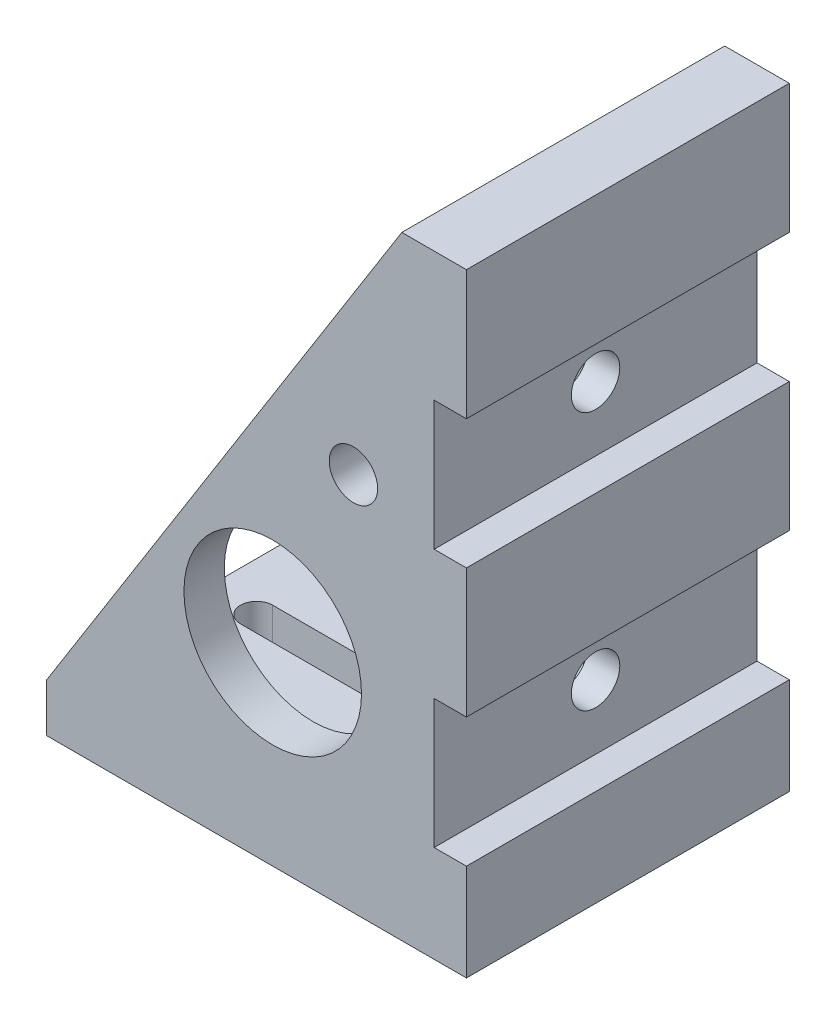
from build123d import *

# Parameters (mm, degrees)
BOSS_EXTRUDE1_DEPTH = 20
SKETCH2_W           = 20
SKETCH2_H           = 8
CUT_EXTRUDE1_DEPTH  = 2
SKETCH4_W           = 15
SKETCH4_H           = 35
CUT_EXTRUDE2_DEPTH  = 22
SKETCH5_R           = 1.5
SKETCH5_R_2         = 5.5
CUT_EXTRUDE3_DEPTH  = 20
SKETCH6_R           = 1.5
CUT_EXTRUDE4_DEPTH  = 2
CUT_EXTRUDE5_DEPTH  = 3


with BuildPart() as part:
    # Sketch1 → Boss-Extrude1 (new body)
    with BuildSketch(Plane.XY):
        Polygon((-13, 0), (13, 0), (13, 38), (9, 38), (-13, 3), align=None)
    extrude(amount=BOSS_EXTRUDE1_DEPTH)

    # Sketch2 → Cut-Extrude1 (cut)
    with BuildSketch(Plane(origin=(13, 0, 0), x_dir=(0, 0, -1), z_dir=(1, 0, 0))):
        with Locations((-10, 10)):
            Rectangle(SKETCH2_W, SKETCH2_H)
        with Locations((-10, 26)):
            Rectangle(SKETCH2_W, SKETCH2_H)
    extrude(amount=-CUT_EXTRUDE1_DEPTH, mode=Mode.SUBTRACT)

    # Sketch4 → Cut-Extrude2 (cut)
    with BuildSketch(Plane.ZY.offset(13)):
        with Locations((10, 20.5)):
            Rectangle(SKETCH4_W, SKETCH4_H)
    extrude(amount=-CUT_EXTRUDE2_DEPTH, mode=Mode.SUBTRACT)

    # Sketch5 → Cut-Extrude3 (cut)
    with BuildSketch(Plane.XY.offset(20)):
        with Locations((6, 23.5)):
            Circle(SKETCH5_R)
        with Locations((1, 12)):
            Circle(SKETCH5_R_2)
    extrude(amount=-CUT_EXTRUDE3_DEPTH, mode=Mode.SUBTRACT)

    # Sketch6 → Cut-Extrude4 (cut)
    with BuildSketch(Plane(origin=(11, 0, 0), x_dir=(0, 0, -1), z_dir=(1, 0, 0))):
        with Locations((-10, 26)):
            Circle(SKETCH6_R)
        with Locations((-10, 10)):
            Circle(SKETCH6_R)
    extrude(amount=-CUT_EXTRUDE4_DEPTH, mode=Mode.SUBTRACT)

    # Sketch7 → Cut-Extrude5 (cut)
    with BuildSketch(Plane(origin=(0, 3, 0), x_dir=(1, 0, 0), z_dir=(0, 1, 0))):
        with BuildLine():
            Line((-10, -9), (6, -9))
            ThreePointArc((6, -9), (7, -10), (6, -11))
            Line((6, -11), (-10, -11))
            ThreePointArc((-10, -11), (-11, -10), (-10, -9))
        make_face()
    extrude(amount=-CUT_EXTRUDE5_DEPTH, mode=Mode.SUBTRACT)


solid = part.part
